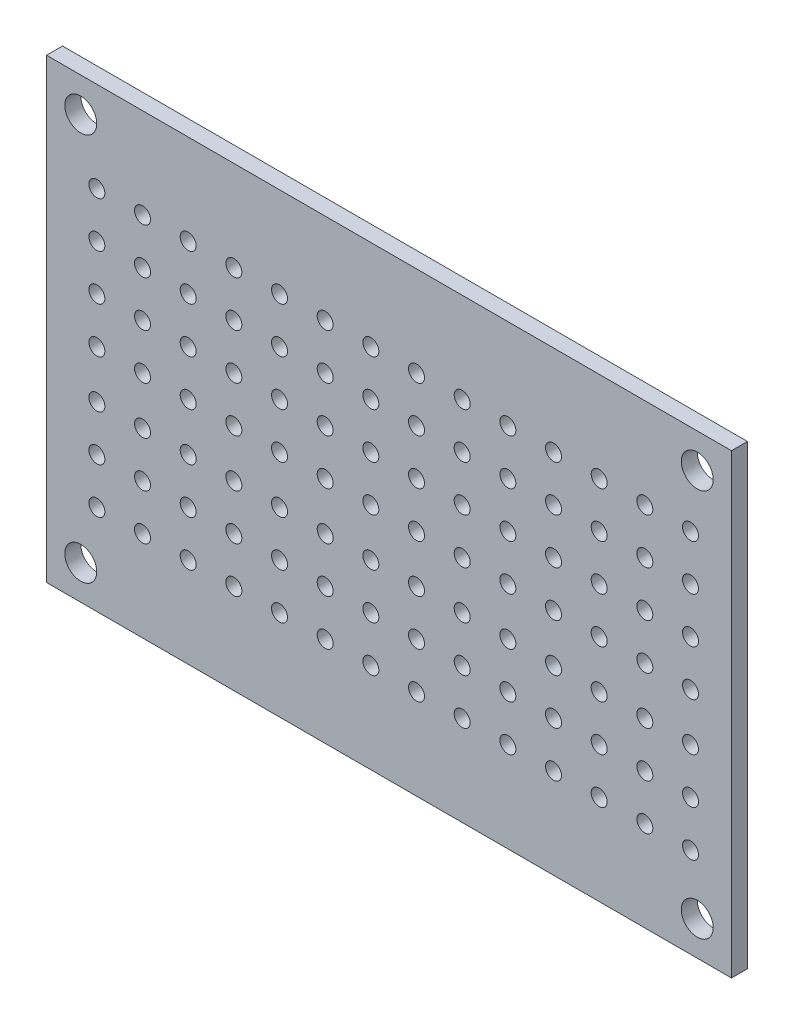
from build123d import *

# Parameters (mm, degrees)
SKETCH1_W           = 76.2
SKETCH1_H           = 50.8
SKETCH1_R           = 1.778
BOSS_EXTRUDE1_DEPTH = 1.778
SKETCH2_R           = 0.889
CUT_EXTRUDE1_DEPTH  = 2.778


with BuildPart() as part:
    # Sketch1 → Boss-Extrude1 (new body)
    with BuildSketch(Plane.XY):
        Rectangle(SKETCH1_W, SKETCH1_H)
        with Locations((-34.29, 21.59)):
            Circle(SKETCH1_R, mode=Mode.SUBTRACT)
        with Locations((-34.29, -21.59)):
            Circle(SKETCH1_R, mode=Mode.SUBTRACT)
        with Locations((34.29, 21.59)):
            Circle(SKETCH1_R, mode=Mode.SUBTRACT)
        with Locations((34.29, -21.59)):
            Circle(SKETCH1_R, mode=Mode.SUBTRACT)
    extrude(amount=BOSS_EXTRUDE1_DEPTH)

    # Sketch2 → Cut-Extrude1 (cut, through all)
    with BuildSketch(Plane(origin=(0, 0, 0), x_dir=(-1, 0, 0), z_dir=(0, 0, -1))):
        with Locations((27.420334743, 15.353983533)):
            Circle(SKETCH2_R)
        with Locations((32.500334743, 15.353983533)):
            Circle(SKETCH2_R)
        with Locations((27.420334743, 10.273983533)):
            Circle(SKETCH2_R)
        with Locations((32.500334743, 10.273983533)):
            Circle(SKETCH2_R)
        with Locations((17.260334743, 15.353983533)):
            Circle(SKETCH2_R)
        with Locations((22.340334743, 15.353983533)):
            Circle(SKETCH2_R)
        with Locations((17.260334743, 10.273983533)):
            Circle(SKETCH2_R)
        with Locations((22.340334743, 10.273983533)):
            Circle(SKETCH2_R)
        with Locations((17.260334743, 5.193983533)):
            Circle(SKETCH2_R)
        with Locations((22.340334743, 5.193983533)):
            Circle(SKETCH2_R)
        with Locations((17.260334743, 0.113983533)):
            Circle(SKETCH2_R)
        with Locations((22.340334743, 0.113983533)):
            Circle(SKETCH2_R)
        with Locations((7.100334743, 15.353983533)):
            Circle(SKETCH2_R)
        with Locations((12.180334743, 15.353983533)):
            Circle(SKETCH2_R)
        with Locations((7.100334743, 10.273983533)):
            Circle(SKETCH2_R)
        with Locations((12.180334743, 10.273983533)):
            Circle(SKETCH2_R)
        with Locations((7.100334743, 5.193983533)):
            Circle(SKETCH2_R)
        with Locations((12.180334743, 5.193983533)):
            Circle(SKETCH2_R)
        with Locations((7.100334743, 0.113983533)):
            Circle(SKETCH2_R)
        with Locations((12.180334743, 0.113983533)):
            Circle(SKETCH2_R)
        with Locations((-3.059665257, 15.353983533)):
            Circle(SKETCH2_R)
        with Locations((2.020334743, 15.353983533)):
            Circle(SKETCH2_R)
        with Locations((27.420334743, 5.193983533)):
            Circle(SKETCH2_R)
        with Locations((32.500334743, 5.193983533)):
            Circle(SKETCH2_R)
        with Locations((27.420334743, 0.113983533)):
            Circle(SKETCH2_R)
        with Locations((32.500334743, 0.113983533)):
            Circle(SKETCH2_R)
        with Locations((-3.059665257, 10.273983533)):
            Circle(SKETCH2_R)
        with Locations((2.020334743, 10.273983533)):
            Circle(SKETCH2_R)
        with Locations((-3.059665257, 5.193983533)):
            Circle(SKETCH2_R)
        with Locations((2.020334743, 5.193983533)):
            Circle(SKETCH2_R)
        with Locations((-3.059665257, 0.113983533)):
            Circle(SKETCH2_R)
        with Locations((2.020334743, 0.113983533)):
            Circle(SKETCH2_R)
        with Locations((-13.219665257, 15.353983533)):
            Circle(SKETCH2_R)
        with Locations((-8.139665257, 15.353983533)):
            Circle(SKETCH2_R)
        with Locations((-13.219665257, 10.273983533)):
            Circle(SKETCH2_R)
        with Locations((-8.139665257, 10.273983533)):
            Circle(SKETCH2_R)
        with Locations((-13.219665257, 5.193983533)):
            Circle(SKETCH2_R)
        with Locations((-8.139665257, 5.193983533)):
            Circle(SKETCH2_R)
        with Locations((-13.219665257, 0.113983533)):
            Circle(SKETCH2_R)
        with Locations((-8.139665257, 0.113983533)):
            Circle(SKETCH2_R)
        with Locations((-23.379665257, 15.353983533)):
            Circle(SKETCH2_R)
        with Locations((-18.299665257, 15.353983533)):
            Circle(SKETCH2_R)
        with Locations((-23.379665257, 10.273983533)):
            Circle(SKETCH2_R)
        with Locations((-18.299665257, 10.273983533)):
            Circle(SKETCH2_R)
        with Locations((-23.379665257, 5.193983533)):
            Circle(SKETCH2_R)
        with Locations((-18.299665257, 5.193983533)):
            Circle(SKETCH2_R)
        with Locations((-23.379665257, 0.113983533)):
            Circle(SKETCH2_R)
        with Locations((-18.299665257, 0.113983533)):
            Circle(SKETCH2_R)
        with Locations((-33.539665257, 15.353983533)):
            Circle(SKETCH2_R)
        with Locations((-28.459665257, 15.353983533)):
            Circle(SKETCH2_R)
        with Locations((-33.539665257, 10.273983533)):
            Circle(SKETCH2_R)
        with Locations((-28.459665257, 10.273983533)):
            Circle(SKETCH2_R)
        with Locations((-33.539665257, 5.193983533)):
            Circle(SKETCH2_R)
        with Locations((-28.459665257, 5.193983533)):
            Circle(SKETCH2_R)
        with Locations((-33.539665257, 0.113983533)):
            Circle(SKETCH2_R)
        with Locations((-28.459665257, 0.113983533)):
            Circle(SKETCH2_R)
        with Locations((-28.459665257, -5.193983533)):
            Circle(SKETCH2_R)
        with Locations((-33.539665257, -5.193983533)):
            Circle(SKETCH2_R)
        with Locations((-28.459665257, -10.273983533)):
            Circle(SKETCH2_R)
        with Locations((-33.539665257, -10.273983533)):
            Circle(SKETCH2_R)
        with Locations((-28.459665257, -15.353983533)):
            Circle(SKETCH2_R)
        with Locations((-33.539665257, -15.353983533)):
            Circle(SKETCH2_R)
        with Locations((-18.299665257, -5.193983533)):
            Circle(SKETCH2_R)
        with Locations((-23.379665257, -5.193983533)):
            Circle(SKETCH2_R)
        with Locations((-18.299665257, -10.273983533)):
            Circle(SKETCH2_R)
        with Locations((-23.379665257, -10.273983533)):
            Circle(SKETCH2_R)
        with Locations((-18.299665257, -15.353983533)):
            Circle(SKETCH2_R)
        with Locations((-23.379665257, -15.353983533)):
            Circle(SKETCH2_R)
        with Locations((-8.139665257, -5.193983533)):
            Circle(SKETCH2_R)
        with Locations((-13.219665257, -5.193983533)):
            Circle(SKETCH2_R)
        with Locations((-8.139665257, -10.273983533)):
            Circle(SKETCH2_R)
        with Locations((-13.219665257, -10.273983533)):
            Circle(SKETCH2_R)
        with Locations((-8.139665257, -15.353983533)):
            Circle(SKETCH2_R)
        with Locations((-13.219665257, -15.353983533)):
            Circle(SKETCH2_R)
        with Locations((2.020334743, -5.193983533)):
            Circle(SKETCH2_R)
        with Locations((-3.059665257, -5.193983533)):
            Circle(SKETCH2_R)
        with Locations((2.020334743, -10.273983533)):
            Circle(SKETCH2_R)
        with Locations((-3.059665257, -10.273983533)):
            Circle(SKETCH2_R)
        with Locations((32.500334743, -5.193983533)):
            Circle(SKETCH2_R)
        with Locations((27.420334743, -5.193983533)):
            Circle(SKETCH2_R)
        with Locations((2.020334743, -15.353983533)):
            Circle(SKETCH2_R)
        with Locations((-3.059665257, -15.353983533)):
            Circle(SKETCH2_R)
        with Locations((12.180334743, -5.193983533)):
            Circle(SKETCH2_R)
        with Locations((7.100334743, -5.193983533)):
            Circle(SKETCH2_R)
        with Locations((12.180334743, -10.273983533)):
            Circle(SKETCH2_R)
        with Locations((7.100334743, -10.273983533)):
            Circle(SKETCH2_R)
        with Locations((12.180334743, -15.353983533)):
            Circle(SKETCH2_R)
        with Locations((7.100334743, -15.353983533)):
            Circle(SKETCH2_R)
        with Locations((22.340334743, -5.193983533)):
            Circle(SKETCH2_R)
        with Locations((17.260334743, -5.193983533)):
            Circle(SKETCH2_R)
        with Locations((22.340334743, -10.273983533)):
            Circle(SKETCH2_R)
        with Locations((17.260334743, -10.273983533)):
            Circle(SKETCH2_R)
        with Locations((22.340334743, -15.353983533)):
            Circle(SKETCH2_R)
        with Locations((17.260334743, -15.353983533)):
            Circle(SKETCH2_R)
        with Locations((32.500334743, -10.273983533)):
            Circle(SKETCH2_R)
        with Locations((27.420334743, -10.273983533)):
            Circle(SKETCH2_R)
        with Locations((32.500334743, -15.353983533)):
            Circle(SKETCH2_R)
        with Locations((27.420334743, -15.353983533)):
            Circle(SKETCH2_R)
    extrude(amount=-CUT_EXTRUDE1_DEPTH, mode=Mode.SUBTRACT)


solid = part.part
